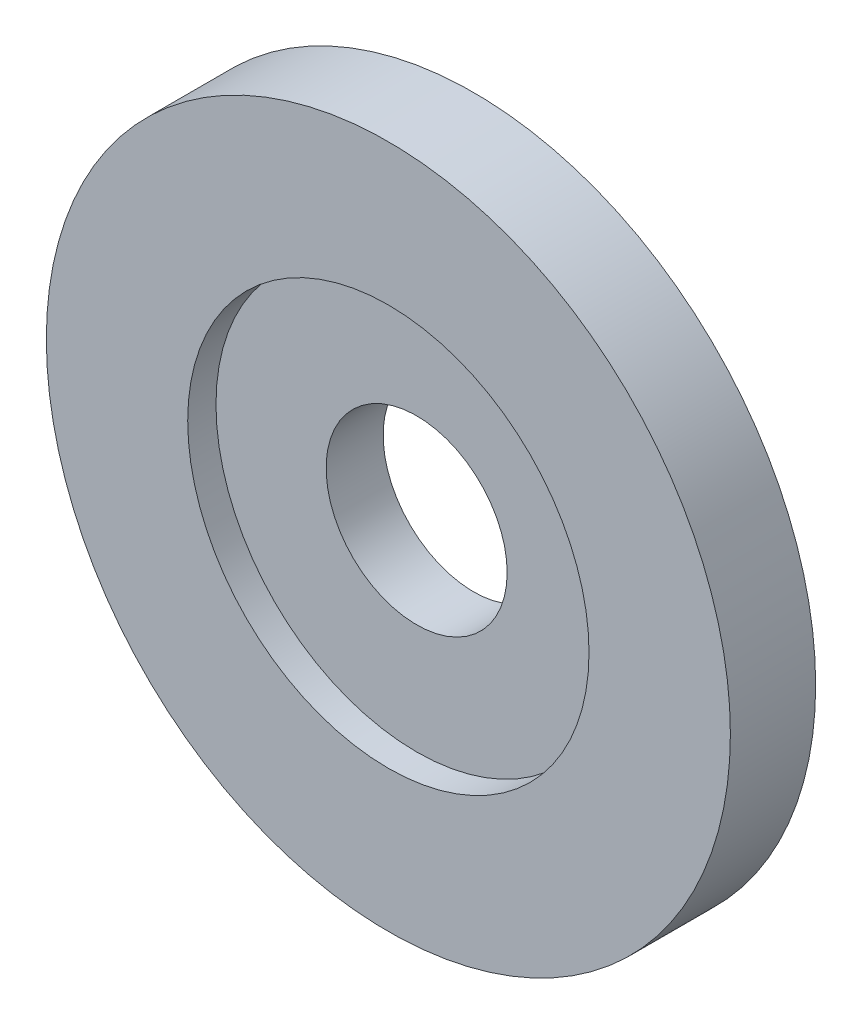
from build123d import *

# Parameters (mm, degrees)
SKETCH1_R           = 19.05
SKETCH1_R_2         = 5.0419
BOSS_EXTRUDE1_DEPTH = 3.175
SKETCH2_R           = 19.05
SKETCH2_R_2         = 11.176
BOSS_EXTRUDE2_DEPTH = 1.5748


with BuildPart() as part:
    # Sketch1 → Boss-Extrude1 (new body)
    with BuildSketch(Plane.XY):
        with Locations((-35.268404938, -193.371995598)):
            Circle(SKETCH1_R)
        with Locations((-35.268404938, -193.371995598)):
            Circle(SKETCH1_R_2, mode=Mode.SUBTRACT)
    extrude(amount=BOSS_EXTRUDE1_DEPTH)

    # Sketch2 → Boss-Extrude2 (add)
    with BuildSketch(Plane.XY.offset(3.175)):
        with Locations((-35.268404938, -193.371995598)):
            Circle(SKETCH2_R)
        with Locations((-35.268404938, -193.371995598)):
            Circle(SKETCH2_R_2, mode=Mode.SUBTRACT)
    extrude(amount=BOSS_EXTRUDE2_DEPTH)


solid = part.part
